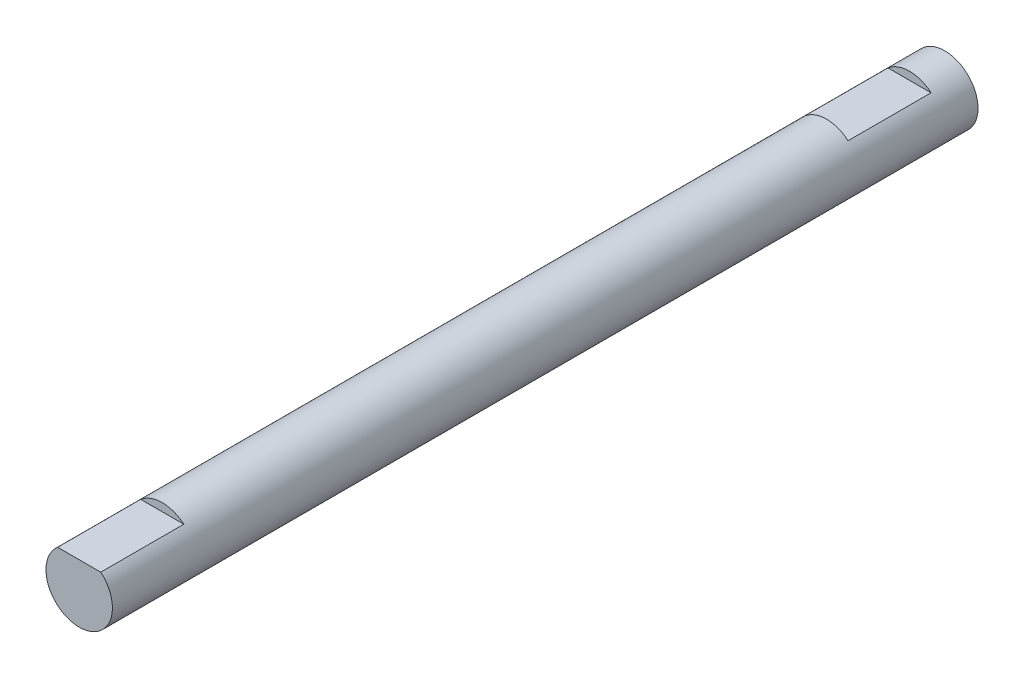
from build123d import *

# Parameters (mm, degrees)
SKETCH_1_R          = 4
EXTRUDE_1_DEPTH     = 104.25
CUT_EXTRUDE_1_DEPTH = 10


with BuildPart() as part:
    # 草图1 → 凸台-拉伸1 (new body)
    with BuildSketch(Plane.XY):
        with Locations((2.788805167, 15.198988159)):
            Circle(SKETCH_1_R)
    extrude(amount=EXTRUDE_1_DEPTH)

    # 草图2 → 切除-拉伸1 (cut)
    with BuildSketch(Plane.XY.offset(104.25)):
        Polygon((-1.211194833, 18.241175928), (6.788805167, 18.241175928), (6.788805167, 20.490551127), (-1.353486866, 20.490551127), (-1.451820208, 18.241175928), align=None)
    cut_extrude_1 = extrude(amount=-CUT_EXTRUDE_1_DEPTH, mode=Mode.SUBTRACT)

    # 镜向1: 切除-拉伸1 across plane
    add(cut_extrude_1.mirror(Plane.XY.offset(54.25)), mode=Mode.SUBTRACT)


solid = part.part
